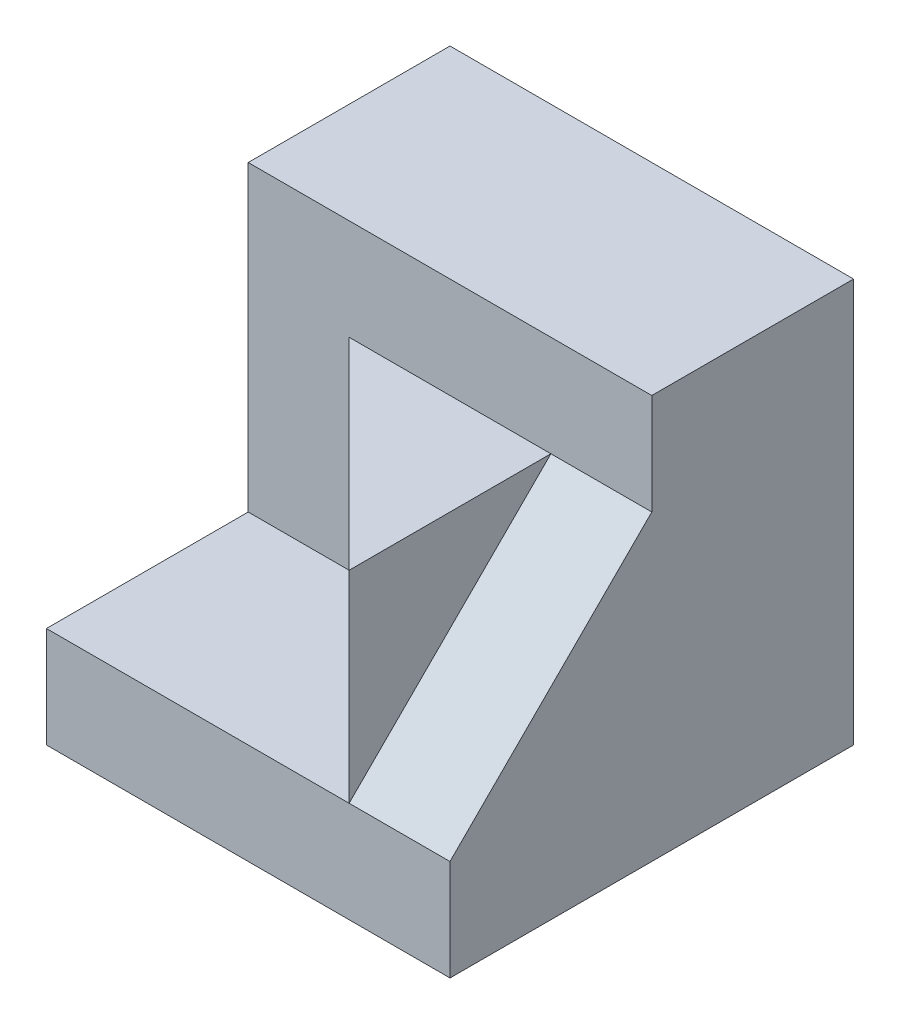
from build123d import *

# Parameters (mm, degrees)
SKETCH1_W           = 4
SKETCH1_H           = 4
BOSS_EXTRUDE1_DEPTH = 4
SKETCH2_W           = 1
SKETCH2_H           = 2
CUT_EXTRUDE1_DEPTH  = 3
SKETCH4_W           = 3
SKETCH4_H           = 2
CUT_EXTRUDE2_DEPTH  = 1
BOSS_EXTRUDE2_DEPTH = 1


with BuildPart() as part:
    # Sketch1 → Boss-Extrude1 (new body)
    with BuildSketch(Plane(origin=(0, 0, 0), x_dir=(0, 0, -1), z_dir=(1, 0, 0))):
        with Locations((2, 2)):
            Rectangle(SKETCH1_W, SKETCH1_H)
    extrude(amount=BOSS_EXTRUDE1_DEPTH)

    # Sketch2 → Cut-Extrude1 (cut)
    with BuildSketch(Plane(origin=(0, 4, 0), x_dir=(1, 0, 0), z_dir=(0, 1, 0))):
        Polygon((0, 0), (3, 0), (1, 2), (0, 2), align=None)
        with Locations((3.5, 1)):
            Rectangle(SKETCH2_W, SKETCH2_H)
    extrude(amount=-CUT_EXTRUDE1_DEPTH, mode=Mode.SUBTRACT)

    # Sketch4 → Cut-Extrude2 (cut)
    with BuildSketch(Plane(origin=(0, 4, 0), x_dir=(1, 0, 0), z_dir=(0, 1, 0))):
        with Locations((2.5, 1)):
            Rectangle(SKETCH4_W, SKETCH4_H)
    extrude(amount=-CUT_EXTRUDE2_DEPTH, mode=Mode.SUBTRACT)

    # Sketch5 → Boss-Extrude2 (add)
    with BuildSketch(Plane(origin=(3, 0, 0), x_dir=(0, 0, -1), z_dir=(1, 0, 0))):
        Polygon((0, 1), (2, 3), (2, 1), align=None)
    extrude(amount=BOSS_EXTRUDE2_DEPTH)


solid = part.part
